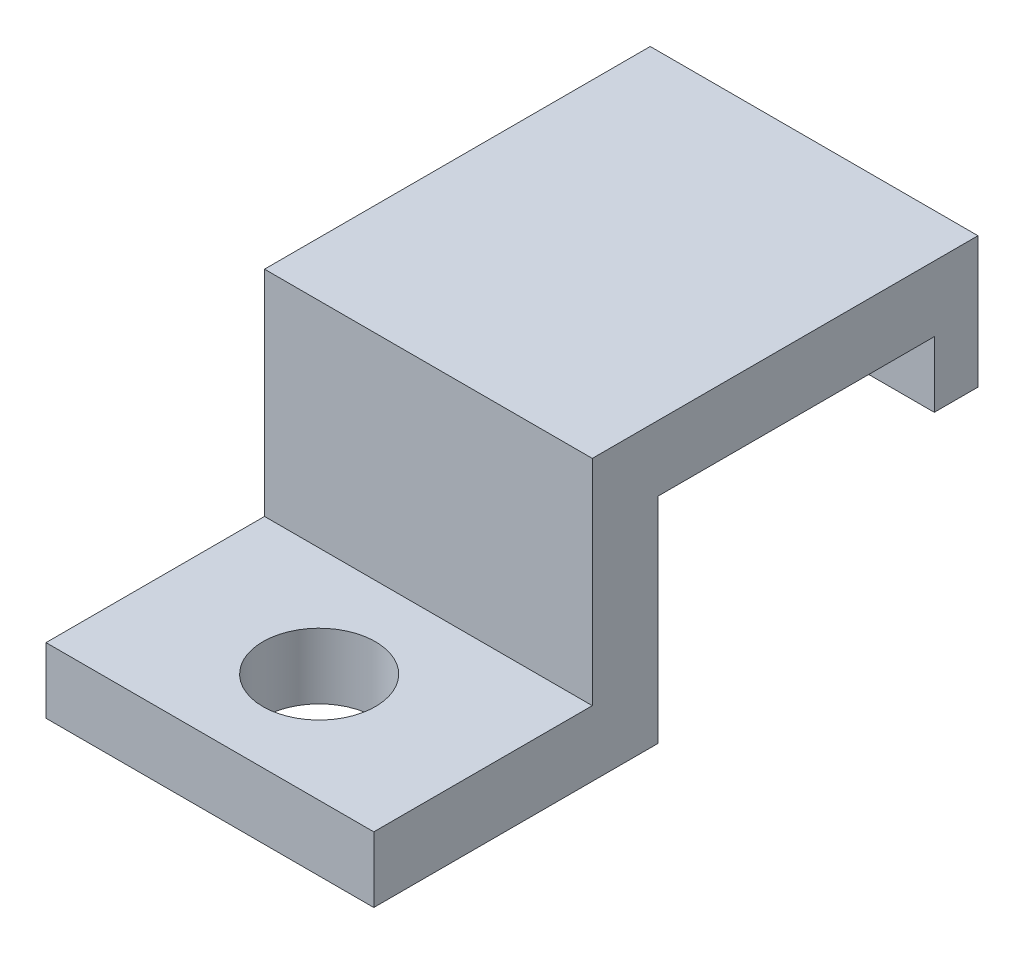
from build123d import *

# Parameters (mm, degrees)
SALIENTE_EXTRUIR1_DEPTH = 15
CROQUIS4_W              = 2
CROQUIS4_H              = 6
SALIENTE_EXTRUIR2_DEPTH = 15
CROQUIS5_R              = 2.575
CORTAR_EXTRUIR1_DEPTH   = 4


with BuildPart() as part:
    # Croquis2 → Saliente-Extruir1 (new body)
    with BuildSketch(Plane(origin=(0, 0, 0), x_dir=(0, 0, -1), z_dir=(1, 0, 0))):
        Polygon((0, 0), (13, 0), (13, 9.8), (25.65, 9.8), (25.65, 12.8), (10, 12.8), (10, 3), (0, 3), align=None)
    extrude(amount=SALIENTE_EXTRUIR1_DEPTH)

    # Croquis4 → Saliente-Extruir2 (add, through all)
    with BuildSketch(Plane(origin=(0, 0, 0), x_dir=(0, 0, -1), z_dir=(1, 0, 0))):
        with Locations((26.65, 9.8)):
            Rectangle(CROQUIS4_W, CROQUIS4_H)
    extrude(amount=SALIENTE_EXTRUIR2_DEPTH)

    # Croquis5 → Cortar-Extruir1 (cut, through all)
    with BuildSketch(Plane(origin=(0, 3, 0), x_dir=(1, 0, 0), z_dir=(0, 1, 0))):
        with Locations((7.5, 5)):
            Circle(CROQUIS5_R)
    extrude(amount=-CORTAR_EXTRUIR1_DEPTH, mode=Mode.SUBTRACT)


solid = part.part
